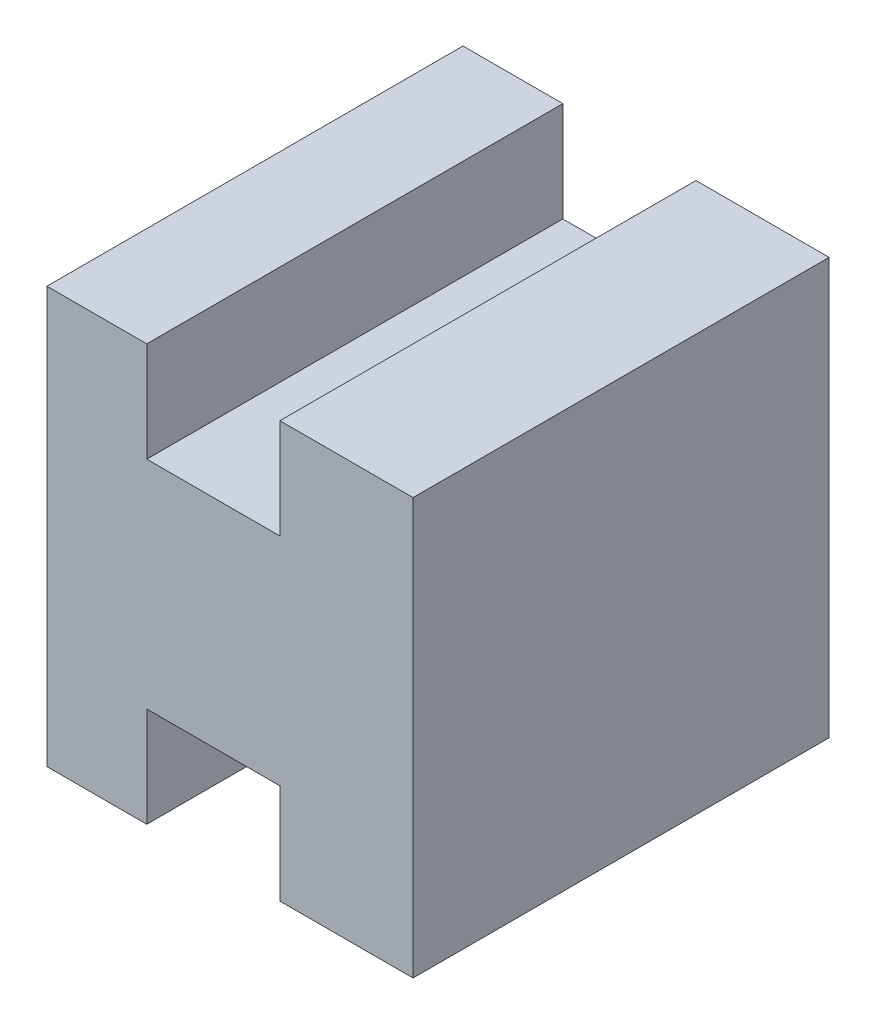
from build123d import *

# Parameters (mm, degrees)
BOSS_EXTRUDE2_DEPTH = 12.5


with BuildPart() as part:
    # Sketch1 → Boss-Extrude2 (new body)
    with BuildSketch(Plane.XY):
        Polygon((-90.614577373, 45.459408198), (-87.614577373, 45.459408198), (-87.614577373, 42.459408198), (-83.614577373, 42.459408198), (-83.614577373, 45.459408198), (-79.614577373, 45.459408198), (-79.614577373, 32.959408198), (-83.614577373, 32.959408198), (-83.614577373, 35.959408198), (-87.614577373, 35.959408198), (-87.614577373, 32.959408198), (-90.614577373, 32.959408198), align=None)
    extrude(amount=BOSS_EXTRUDE2_DEPTH)


solid = part.part
